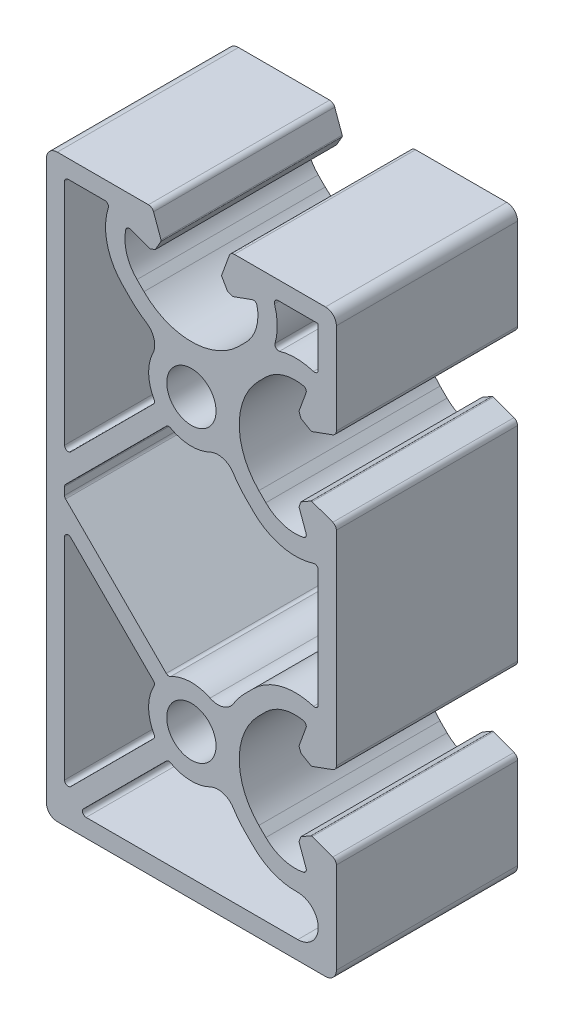
from build123d import *

# Parameters (mm, degrees)
SK_MAIN_EXTRUSION_R  = 3.4
MAIN_EXTRUSION_DEPTH = 25


with BuildPart() as part:
    # Sk Main Extrusion → Main Extrusion (new body)
    with BuildSketch(Plane.XY):
        with BuildLine():
            Line((16.671180212, -15.809923155), (19.506515107, -14.777945649))
            ThreePointArc((19.506515107, -14.777945649), (19.864364033, -14.503358511), (20, -14.073176184))
            Line((20, -14.073176184), (20, 14.073176184))
            ThreePointArc((20, 14.073176184), (19.864364033, 14.503358511), (19.506515107, 14.777945649))
            Line((19.506515107, 14.777945649), (16.671180212, 15.809923155))
            ThreePointArc((16.671180212, 15.809923155), (16.563886241, 15.824048675), (16.460675177, 15.791506351))
            Line((16.460675177, 15.791506351), (15.111296024, 15.012441934))
            Line((15.111296024, 15.012441934), (14.845251581, 14.281490834))
            Line((14.845251581, 14.281490834), (15.81984631, 11.603813821))
            ThreePointArc((15.81984631, 11.603813821), (15.786489799, 11.188925388), (15.450654467, 10.943039849))
            ThreePointArc((15.450654467, 10.943039849), (12.665882372, 11.066566987), (10.272684887, 12.495839661))
            Line((10.272684887, 12.495839661), (9.309262274, 13.459262274))
            ThreePointArc((9.309262274, 13.459262274), (6.6, 20), (9.309262274, 26.540737726))
            Line((9.309262274, 26.540737726), (10.272684887, 27.504160339))
            ThreePointArc((10.272684887, 27.504160339), (12.665882372, 28.933433013), (15.450654467, 29.056960151))
            ThreePointArc((15.450654467, 29.056960151), (15.786489799, 28.811074612), (15.81984631, 28.396186179))
            Line((15.81984631, 28.396186179), (14.845251581, 25.718509166))
            Line((14.845251581, 25.718509166), (15.111296024, 24.987558066))
            Line((15.111296024, 24.987558066), (16.460675177, 24.208493649))
            ThreePointArc((16.460675177, 24.208493649), (16.563886241, 24.175951325), (16.671180212, 24.190076845))
            Line((16.671180212, 24.190076845), (19.506515107, 25.222054351))
            ThreePointArc((19.506515107, 25.222054351), (19.864364033, 25.496641489), (20, 25.926823816))
            Line((20, 25.926823816), (20, 38.5))
            ThreePointArc((20, 38.5), (19.560660172, 39.560660172), (18.5, 40))
            Line((18.5, 40), (5.926823816, 40))
            ThreePointArc((5.926823816, 40), (5.496641489, 39.864364033), (5.222054351, 39.506515107))
            Line((5.222054351, 39.506515107), (4.190076845, 36.671180212))
            ThreePointArc((4.190076845, 36.671180212), (4.175951325, 36.563886241), (4.208493649, 36.460675177))
            Line((4.208493649, 36.460675177), (4.987558066, 35.111296024))
            Line((4.987558066, 35.111296024), (5.718509166, 34.845251581))
            Line((5.718509166, 34.845251581), (8.396186179, 35.81984631))
            ThreePointArc((8.396186179, 35.81984631), (8.811074612, 35.786489799), (9.056960151, 35.450654467))
            ThreePointArc((9.056960151, 35.450654467), (8.933433013, 32.665882372), (7.504160339, 30.272684887))
            Line((7.504160339, 30.272684887), (6.540737726, 29.309262274))
            ThreePointArc((6.540737726, 29.309262274), (0, 26.6), (-6.540737726, 29.309262274))
            Line((-6.540737726, 29.309262274), (-7.504160339, 30.272684887))
            ThreePointArc((-7.504160339, 30.272684887), (-8.933433013, 32.665882372), (-9.056960151, 35.450654467))
            ThreePointArc((-9.056960151, 35.450654467), (-8.811074612, 35.786489799), (-8.396186179, 35.81984631))
            Line((-8.396186179, 35.81984631), (-5.718509166, 34.845251581))
            Line((-5.718509166, 34.845251581), (-4.987558066, 35.111296024))
            Line((-4.987558066, 35.111296024), (-4.208493649, 36.460675177))
            ThreePointArc((-4.208493649, 36.460675177), (-4.175951325, 36.563886241), (-4.190076845, 36.671180212))
            Line((-4.190076845, 36.671180212), (-5.222054351, 39.506515107))
            ThreePointArc((-5.222054351, 39.506515107), (-5.496641489, 39.864364033), (-5.926823816, 40))
            Line((-5.926823816, 40), (-18.5, 40))
            ThreePointArc((-18.5, 40), (-19.560660172, 39.560660172), (-20, 38.5))
            Line((-20, 38.5), (-20, -38.5))
            ThreePointArc((-20, -38.5), (-19.560660172, -39.560660172), (-18.5, -40))
            Line((-18.5, -40), (18.5, -40))
            ThreePointArc((18.5, -40), (19.560660172, -39.560660172), (20, -38.5))
            Line((20, -38.5), (20, -25.926823816))
            ThreePointArc((20, -25.926823816), (19.864364033, -25.496641489), (19.506515107, -25.222054351))
            Line((19.506515107, -25.222054351), (16.671180212, -24.190076845))
            ThreePointArc((16.671180212, -24.190076845), (16.563886241, -24.175951325), (16.460675177, -24.208493649))
            Line((16.460675177, -24.208493649), (15.111296024, -24.987558066))
            Line((15.111296024, -24.987558066), (14.845251581, -25.718509166))
            Line((14.845251581, -25.718509166), (15.81984631, -28.396186179))
            ThreePointArc((15.81984631, -28.396186179), (15.786489799, -28.811074612), (15.450654467, -29.056960151))
            ThreePointArc((15.450654467, -29.056960151), (12.665882372, -28.933433013), (10.272684887, -27.504160339))
            Line((10.272684887, -27.504160339), (9.309262274, -26.540737726))
            ThreePointArc((9.309262274, -26.540737726), (6.6, -20), (9.309262274, -13.459262274))
            Line((9.309262274, -13.459262274), (10.272684887, -12.495839661))
            ThreePointArc((10.272684887, -12.495839661), (12.665882372, -11.066566987), (15.450654467, -10.943039849))
            ThreePointArc((15.450654467, -10.943039849), (15.786489799, -11.188925388), (15.81984631, -11.603813821))
            Line((15.81984631, -11.603813821), (14.845251581, -14.281490834))
            Line((14.845251581, -14.281490834), (15.111296024, -15.012441934))
            Line((15.111296024, -15.012441934), (16.460675177, -15.791506351))
            ThreePointArc((16.460675177, -15.791506351), (16.563886241, -15.824048675), (16.671180212, -15.809923155))
        make_face()
        with Locations((0, -20)):
            Circle(SK_MAIN_EXTRUSION_R, mode=Mode.SUBTRACT)
        with Locations((0, 20)):
            Circle(SK_MAIN_EXTRUSION_R, mode=Mode.SUBTRACT)
        with BuildLine():
            Line((-17.5, 37), (-17.5, 5.474873734))
            ThreePointArc((-17.5, 5.474873734), (-17.191341716, 5.012933968), (-16.646446609, 5.121320344))
            Line((-16.646446609, 5.121320344), (-5.236899672, 16.530867281))
            ThreePointArc((-5.236899672, 16.530867281), (-5.095239754, 16.81540054), (-5.153698917, 17.127825306))
            ThreePointArc((-5.153698917, 17.127825306), (-5.897648575, 19.833442852), (-5.307583096, 22.576734694))
            ThreePointArc((-5.307583096, 22.576734694), (-5.153883821, 24.359333373), (-6.230846881, 25.788120301))
            ThreePointArc((-6.230846881, 25.788120301), (-7.316529108, 26.555931161), (-8.308504679, 27.441495321))
            Line((-8.308504679, 27.441495321), (-9.444282589, 28.577273231))
            ThreePointArc((-9.444282589, 28.577273231), (-11.611987193, 32.430514315), (-11.464011904, 36.849169473))
            ThreePointArc((-11.464011904, 36.849169473), (-11.537349181, 37.295452819), (-11.940719521, 37.5))
            Line((-11.940719521, 37.5), (-17, 37.5))
            ThreePointArc((-17, 37.5), (-17.353553391, 37.353553391), (-17.5, 37))
        make_face(mode=Mode.SUBTRACT)
        with BuildLine():
            Line((-3.469132719, 14.763100328), (-17.353553391, 0.878679656))
            ThreePointArc((-17.353553391, 0.878679656), (-17.461939766, 0.716467982), (-17.5, 0.525126266))
            Line((-17.5, 0.525126266), (-17.5, -0.525126266))
            ThreePointArc((-17.5, -0.525126266), (-17.461939766, -0.716467982), (-17.353553391, -0.878679656))
            Line((-17.353553391, -0.878679656), (-3.469132719, -14.763100328))
            ThreePointArc((-3.469132719, -14.763100328), (-3.18459946, -14.904760246), (-2.872174694, -14.846301083))
            ThreePointArc((-2.872174694, -14.846301083), (-0.166557148, -14.102351425), (2.576734694, -14.692416904))
            ThreePointArc((2.576734694, -14.692416904), (4.359333373, -14.846116179), (5.788120301, -13.769153119))
            ThreePointArc((5.788120301, -13.769153119), (6.555931161, -12.683470892), (7.441495321, -11.691495321))
            Line((7.441495321, -11.691495321), (8.577273231, -10.555717411))
            ThreePointArc((8.577273231, -10.555717411), (12.430514315, -8.388012807), (16.849169473, -8.535988096))
            ThreePointArc((16.849169473, -8.535988096), (17.295452819, -8.462650819), (17.5, -8.059280479))
            Line((17.5, -8.059280479), (17.5, 8.059280479))
            ThreePointArc((17.5, 8.059280479), (17.295452819, 8.462650819), (16.849169473, 8.535988096))
            ThreePointArc((16.849169473, 8.535988096), (12.430514315, 8.388012807), (8.577273231, 10.555717411))
            Line((8.577273231, 10.555717411), (7.441495321, 11.691495321))
            ThreePointArc((7.441495321, 11.691495321), (6.555931161, 12.683470892), (5.788120301, 13.769153119))
            ThreePointArc((5.788120301, 13.769153119), (4.359333373, 14.846116179), (2.576734694, 14.692416904))
            ThreePointArc((2.576734694, 14.692416904), (-0.166557148, 14.102351425), (-2.872174694, 14.846301083))
            ThreePointArc((-2.872174694, 14.846301083), (-3.18459946, 14.904760246), (-3.469132719, 14.763100328))
        make_face(mode=Mode.SUBTRACT)
        with BuildLine():
            Line((-17.5, -5.474873734), (-17.5, -34.525126266))
            ThreePointArc((-17.5, -34.525126266), (-17.191341716, -34.987066032), (-16.646446609, -34.878679656))
            Line((-16.646446609, -34.878679656), (-5.236899672, -23.469132719))
            ThreePointArc((-5.236899672, -23.469132719), (-5.095239754, -23.18459946), (-5.153698917, -22.872174694))
            ThreePointArc((-5.153698917, -22.872174694), (-5.9, -20), (-5.153698917, -17.127825306))
            ThreePointArc((-5.153698917, -17.127825306), (-5.095239754, -16.81540054), (-5.236899672, -16.530867281))
            Line((-5.236899672, -16.530867281), (-16.646446609, -5.121320344))
            ThreePointArc((-16.646446609, -5.121320344), (-17.191341716, -5.012933968), (-17.5, -5.474873734))
        make_face(mode=Mode.SUBTRACT)
        with BuildLine():
            Line((-3.469132719, -25.236899672), (-14.878679656, -36.646446609))
            ThreePointArc((-14.878679656, -36.646446609), (-14.987066032, -37.191341716), (-14.525126266, -37.5))
            Line((-14.525126266, -37.5), (14.67102413, -37.5))
            ThreePointArc((14.67102413, -37.5), (17.499746132, -34.633125439), (14.59523355, -31.843063688))
            ThreePointArc((14.59523355, -31.843063688), (11.339316504, -31.263177929), (8.577273231, -29.444282589))
            Line((8.577273231, -29.444282589), (7.441495321, -28.308504679))
            ThreePointArc((7.441495321, -28.308504679), (6.555931161, -27.316529108), (5.788120301, -26.230846881))
            ThreePointArc((5.788120301, -26.230846881), (4.359333373, -25.153883821), (2.576734694, -25.307583096))
            ThreePointArc((2.576734694, -25.307583096), (-0.166557148, -25.897648575), (-2.872174694, -25.153698917))
            ThreePointArc((-2.872174694, -25.153698917), (-3.18459946, -25.095239754), (-3.469132719, -25.236899672))
        make_face(mode=Mode.SUBTRACT)
        with BuildLine():
            Line((17.5, 31.940719521), (17.5, 37.5))
            Line((17.5, 37.5), (11.940719521, 37.5))
            ThreePointArc((11.940719521, 37.5), (11.537349181, 37.295452819), (11.464011904, 36.849169473))
            ThreePointArc((11.464011904, 36.849169473), (11.844928721, 34.508523804), (11.540116235, 32.156756572))
            ThreePointArc((11.540116235, 32.156756572), (11.66791097, 31.66791097), (12.156756572, 31.540116235))
            ThreePointArc((12.156756572, 31.540116235), (14.508523804, 31.844928721), (16.849169473, 31.464011904))
            ThreePointArc((16.849169473, 31.464011904), (17.295452819, 31.537349181), (17.5, 31.940719521))
        make_face(mode=Mode.SUBTRACT)
    extrude(amount=-MAIN_EXTRUSION_DEPTH)


solid = part.part
